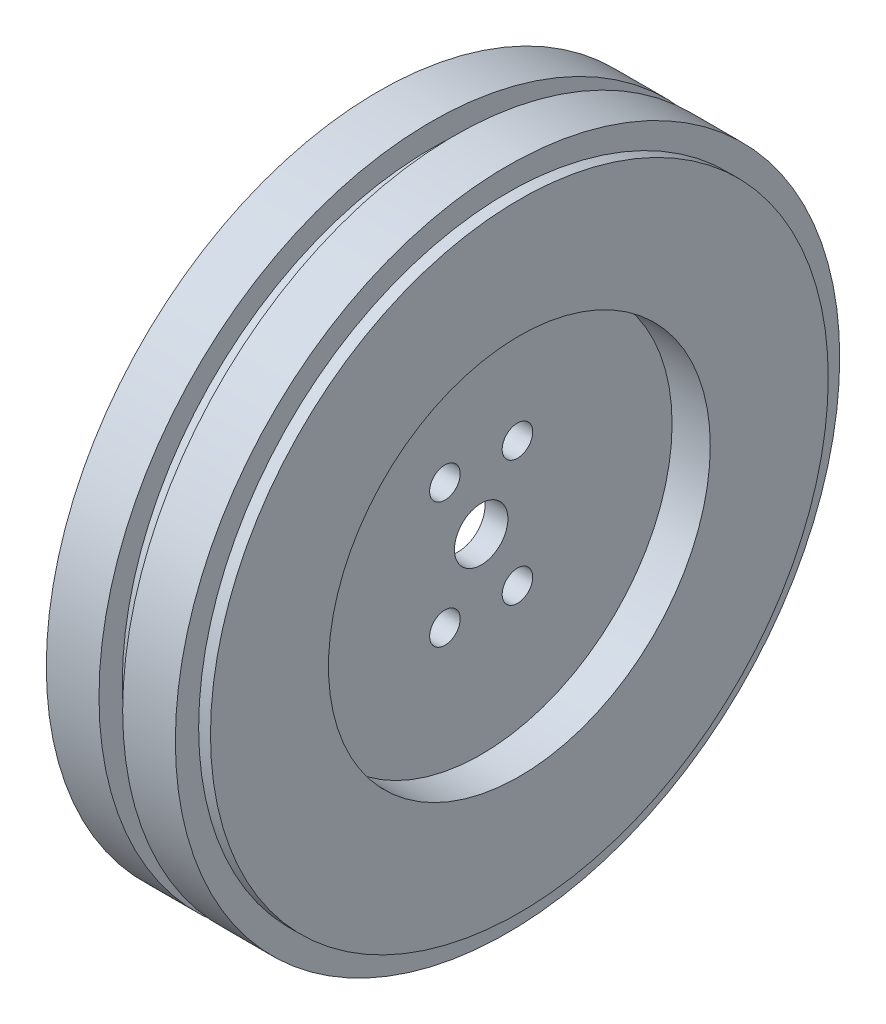
from build123d import *

# Parameters (mm, degrees)
ESQUISSE2_W             = 5
ESQUISSE2_H             = 12.5
ESQUISSE3_R             = 2
ENL_V_MAT_EXTRU_1_DEPTH = 36
ESQUISSE4_R             = 3.5
ENL_V_MAT_EXTRU_2_DEPTH = 36
SKETCH1_R               = 40
CUT_EXTRUDE1_DEPTH      = 20
SKETCH2_R               = 40
SKETCH2_R_2             = 39
BOSS_EXTRUDE2_DEPTH     = 15
SKETCH3_R               = 25
CUT_EXTRUDE2_DEPTH      = 5
SKETCH4_R               = 43.5
SKETCH4_R_2             = 40
BOSS_EXTRUDE3_DEPTH     = 20
SKETCH5_R               = 43.5
SKETCH5_R_2             = 40.45
CUT_EXTRUDE3_DEPTH      = 1.55
SKETCH6_R               = 43.5
SKETCH6_R_2             = 40.45
CUT_EXTRUDE4_DEPTH      = 1.55
CUT_EXTRUDE4_DEPTH_BACK = 1.55
SKETCH7_R               = 43.5
SKETCH7_R_2             = 40.45
CUT_EXTRUDE5_DEPTH      = 1.55


with BuildPart() as part:
    # Esquisse1 → Révolution1 (revolve)
    with BuildSketch(Plane.XY):
        Polygon((0, 34), (0, 0), (8, 0), (8, 40), (3, 40), (3, 39), (-27, 39), (-27, 40), (-32, 40), (-32, 34), align=None)
    revolve(axis=Axis((-49.644499027, 0, 0), (1, 0, 0)))

    # Esquisse2 → Enlèvement de matière-Révolution1 (revolve, cut)
    with BuildSketch(Plane.XY):
        with Locations((5.5, 6.25)):
            Rectangle(ESQUISSE2_W, ESQUISSE2_H)
    revolve(axis=Axis((0, 0, 0), (1, 0, 0)), mode=Mode.SUBTRACT)

    # Esquisse3 → Enlèv. mat.-Extru.1 (cut, through all)
    with BuildSketch(Plane(origin=(3, 0, 0), x_dir=(0, 0, -1), z_dir=(1, 0, 0))):
        with Locations((4.75, 8.227241336)):
            Circle(ESQUISSE3_R)
        with Locations((-4.75, 8.227241336)):
            Circle(ESQUISSE3_R)
        with Locations((4.75, -8.227241336)):
            Circle(ESQUISSE3_R)
        with Locations((-4.75, -8.227241336)):
            Circle(ESQUISSE3_R)
    extrude(amount=-ENL_V_MAT_EXTRU_1_DEPTH, mode=Mode.SUBTRACT)

    # Esquisse4 → Enlèv. mat.-Extru.2 (cut, through all)
    with BuildSketch(Plane(origin=(3, 0, 0), x_dir=(0, 0, -1), z_dir=(1, 0, 0))):
        Circle(ESQUISSE4_R)
    extrude(amount=-ENL_V_MAT_EXTRU_2_DEPTH, mode=Mode.SUBTRACT)

    # Sketch1 → Cut-Extrude1 (cut)
    with BuildSketch(Plane.ZY.offset(32)):
        Circle(SKETCH1_R)
    extrude(amount=-CUT_EXTRUDE1_DEPTH, mode=Mode.SUBTRACT)

    # Sketch2 → Boss-Extrude2 (add)
    with BuildSketch(Plane.ZY.offset(-3)):
        Circle(SKETCH2_R)
        Circle(SKETCH2_R_2, mode=Mode.SUBTRACT)
    extrude(amount=BOSS_EXTRUDE2_DEPTH)

    # Sketch3 → Cut-Extrude2 (cut)
    with BuildSketch(Plane(origin=(8, 0, 0), x_dir=(0, 0, -1), z_dir=(1, 0, 0))):
        Circle(SKETCH3_R)
    extrude(amount=-CUT_EXTRUDE2_DEPTH, mode=Mode.SUBTRACT)

    # Sketch4 → Boss-Extrude3 (add)
    with BuildSketch(Plane.ZY.offset(12)):
        Circle(SKETCH4_R)
        Circle(SKETCH4_R_2, mode=Mode.SUBTRACT)
    extrude(amount=-BOSS_EXTRUDE3_DEPTH)

    # Sketch5 → Cut-Extrude3 (cut)
    with BuildSketch(Plane.ZY.offset(12)):
        Circle(SKETCH5_R)
        Circle(SKETCH5_R_2, mode=Mode.SUBTRACT)
    extrude(amount=-CUT_EXTRUDE3_DEPTH, mode=Mode.SUBTRACT)

    # Sketch6 → Cut-Extrude4 (cut, two sides)
    with BuildSketch(Plane.ZY.offset(2)) as cut_extrude4_sk:
        Circle(SKETCH6_R)
        Circle(SKETCH6_R_2, mode=Mode.SUBTRACT)
    extrude(amount=CUT_EXTRUDE4_DEPTH, mode=Mode.SUBTRACT)
    extrude(cut_extrude4_sk.sketch, amount=-CUT_EXTRUDE4_DEPTH_BACK, mode=Mode.SUBTRACT)

    # Sketch7 → Cut-Extrude5 (cut)
    with BuildSketch(Plane(origin=(8, 0, 0), x_dir=(0, 0, -1), z_dir=(1, 0, 0))):
        Circle(SKETCH7_R)
        Circle(SKETCH7_R_2, mode=Mode.SUBTRACT)
    extrude(amount=-CUT_EXTRUDE5_DEPTH, mode=Mode.SUBTRACT)


solid = part.part
